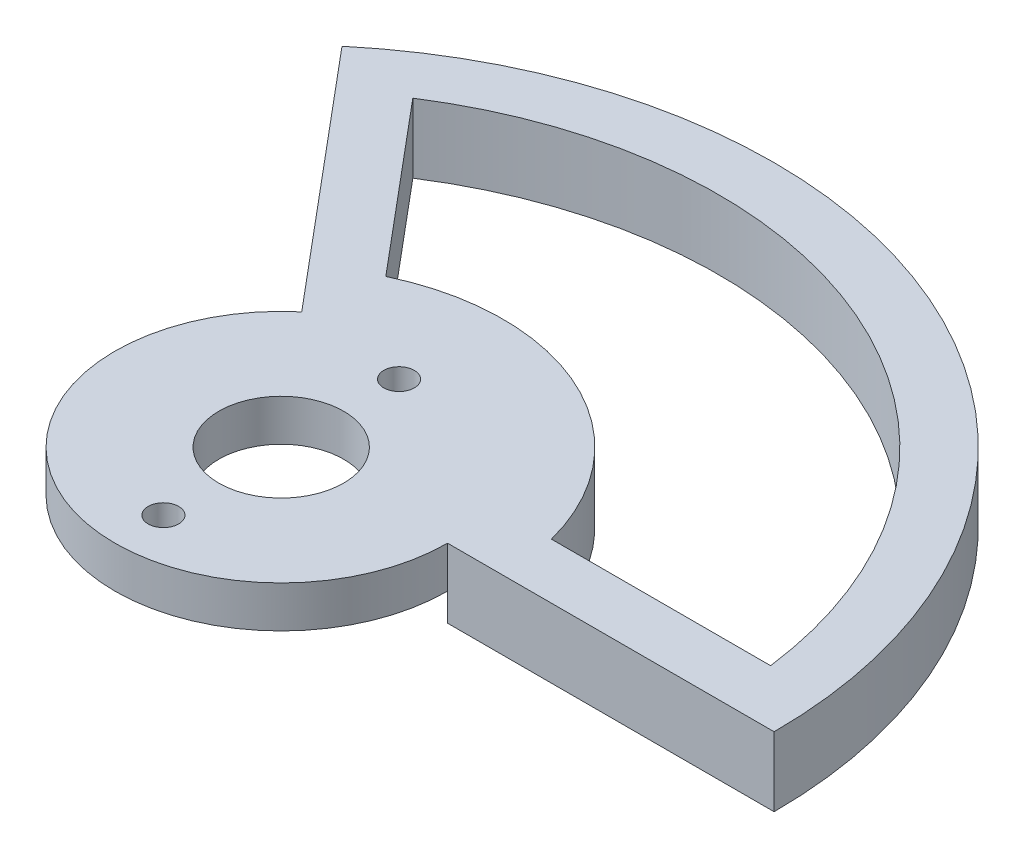
from build123d import *

# Parameters (mm, degrees)
SKETCH1_R           = 12
SKETCH1_R_2         = 4.5
SKETCH1_R_3         = 1.1
BOSS_EXTRUDE1_DEPTH = 3
BOSS_EXTRUDE2_DEPTH = 5
CUT_EXTRUDE1_DEPTH  = 6


with BuildPart() as part:
    # Sketch1 → Boss-Extrude1 (new body)
    with BuildSketch(Plane(origin=(0, 0, 0), x_dir=(1, 0, 0), z_dir=(0, 1, 0))):
        Circle(SKETCH1_R)
        Circle(SKETCH1_R_2, mode=Mode.SUBTRACT)
        with Locations((0, 8.5)):
            Circle(SKETCH1_R_3, mode=Mode.SUBTRACT)
        with Locations((0, -8.5)):
            Circle(SKETCH1_R_3, mode=Mode.SUBTRACT)
    extrude(amount=BOSS_EXTRUDE1_DEPTH)

    # Sketch2 → Boss-Extrude2 (add)
    with BuildSketch(Plane(origin=(0, 3, 0), x_dir=(1, 0, 0), z_dir=(0, 1, 0))):
        with BuildLine():
            Line((12, 0), (35.56, 0))
            ThreePointArc((35.56, 0), (15.028305387, 32.228304907), (-22.8575274, 27.240540397))
            Line((-22.8575274, 27.240540397), (-7.713451316, 9.192533317))
            ThreePointArc((-7.713451316, 9.192533317), (5.071419141, 10.875693444), (12, 0))
        make_face()
    extrude(amount=-BOSS_EXTRUDE2_DEPTH)

    # Sketch3 → Cut-Extrude1 (cut, through all)
    with BuildSketch(Plane.XZ.offset(2)):
        with BuildLine():
            Line((31.305488337, -4), (15.491933385, -4))
            ThreePointArc((15.491933385, -4), (6.761892188, -14.500924593), (-6.893845057, -14.438659921))
            Line((-6.893845057, -14.438659921), (-17.058602246, -26.552545818))
            ThreePointArc((-17.058602246, -26.552545818), (13.337832341, -28.603073759), (31.305488337, -4))
        make_face()
    extrude(amount=-CUT_EXTRUDE1_DEPTH, mode=Mode.SUBTRACT)


solid = part.part
